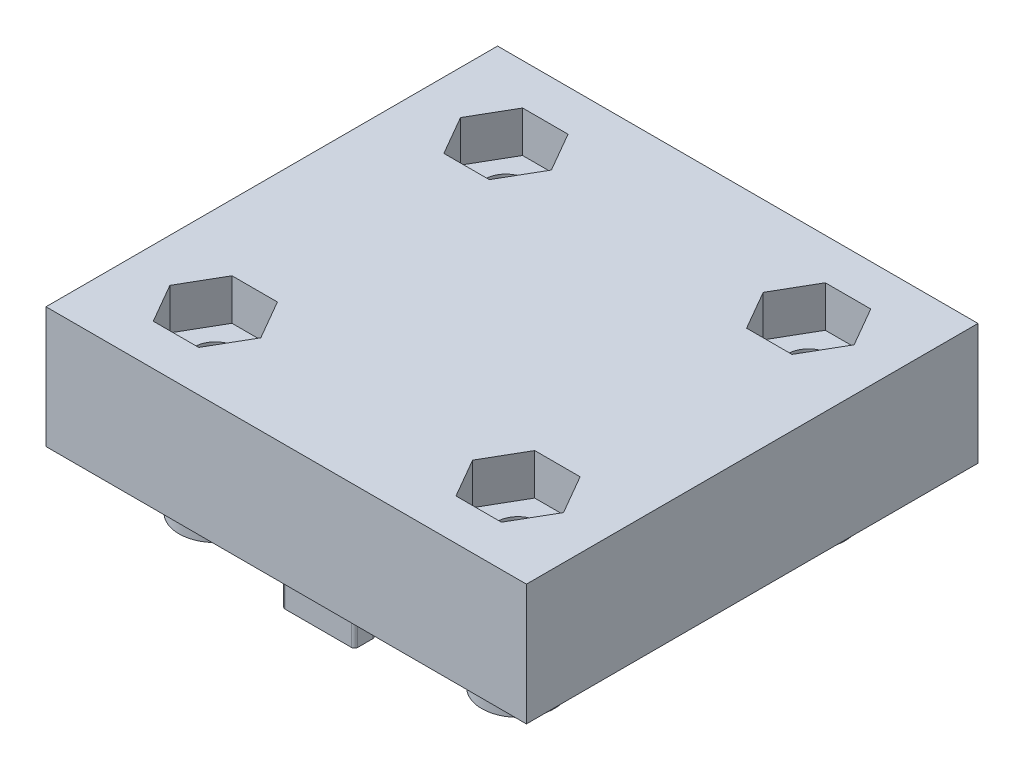
from build123d import *
from OCP.BRepFilletAPI import BRepFilletAPI_MakeChamfer

# Parameters (mm, degrees)
BOSS_EXTRUDE3_DEPTH       = 10
M4_CLEARANCE_HOLE1_D      = 4.5
SKETCH21_R                = 1.118017303
BOSS_EXTRUDE6_DEPTH       = 1
CUT_EXTRUDE11_DEPTH       = 15
SKETCH22_R                = 1.118017303
CUT_EXTRUDE8_DEPTH        = 1
CHAMFER1_SIZE             = 1
CHAMFER1_SIZE2            = 1.035530314
CUT_EXTRUDE10_DEPTH       = 3
SKETCH25_R                = 1.75
CUT_EXTRUDE12_DEPTH       = 76.875514918
CUT_EXTRUDE13_DEPTH       = 3.4
MIRROR3_COPY_1_DEPTH      = 3.4
SKETCH27_R                = 3
SKETCH27_R_2              = 1.7
BOSS_EXTRUDE7_DEPTH       = 4.4
MIRROR5_COPY_1_SKETCH_R   = 3
MIRROR5_COPY_1_SKETCH_R_2 = 1.7
MIRROR5_COPY_1_DEPTH      = 4.4
FILLET3_R                 = 2.1
CUT_EXTRUDE14_DEPTH       = 2
MIRROR7_COPY_1_DEPTH      = 2
CUT_EXTRUDE15_DEPTH       = 4
FILLET6_R                 = 0.25
FILLET7_R                 = 0.25
BOSS_EXTRUDE8_DEPTH       = 4.4
FILLET8_R                 = 0.25
FILLET9_R                 = 1
FILLET10_R                = 0.25
FILLET11_R                = 1
SKETCH32_W                = 148.301652658
SKETCH32_H                = 130.819582074
SKETCH32_W_2              = 39.676110034
SKETCH32_H_2              = 37.292287862
CUT_EXTRUDE16_DEPTH       = 40


with BuildPart() as part:
    # Sketch6 → Boss-Extrude3 (new body)
    with BuildSketch(Plane(origin=(0, 0, 0), x_dir=(1, 0, 0), z_dir=(0, 1, 0))):
        with BuildLine():
            Line((-40, 33.094010768), (40, 33.094010768))
            ThreePointArc((40, 33.094010768), (48.660254038, 28.094010768), (48.660254038, 18.094010768))
            Line((48.660254038, 18.094010768), (28.660254038, -16.547005384))
            Line((28.660254038, -16.547005384), (8.660254038, -51.188021535))
            ThreePointArc((8.660254038, -51.188021535), (0, -56.188021535), (-8.660254038, -51.188021535))
            Line((-8.660254038, -51.188021535), (-28.660254038, -16.547005384))
            Line((-28.660254038, -16.547005384), (-48.660254038, 18.094010768))
            ThreePointArc((-48.660254038, 18.094010768), (-48.660254038, 28.094010768), (-40, 33.094010768))
        make_face()
    extrude(amount=BOSS_EXTRUDE3_DEPTH)

    # M4 Clearance Hole1 (through all)
    with Locations(Plane(origin=(0, 0, 0), x_dir=(-1, 0, 0), z_dir=(0, -1, 0))):
        with Locations((-40, 23.094010768), (40, 23.094010768), (0, -46.188021535)):
            Hole(M4_CLEARANCE_HOLE1_D / 2)

    # Sketch21 → Boss-Extrude6 (add)
    with BuildSketch(Plane(origin=(0, 0, 0), x_dir=(-1, 0, 0), z_dir=(0, -1, 0))):
        with Locations(Location((0, 0, 0), (0, 0, 270))):
            Circle(SKETCH21_R)
    extrude(amount=BOSS_EXTRUDE6_DEPTH)

    # Sketch24 → Cut-Extrude11 (cut, symmetric)
    with BuildSketch(Plane(origin=(0, 0, 0), x_dir=(0, 0, -1), z_dir=(1, 0, 0))):
        Polygon((27.094010768, 10), (33.094010768, 2.214464559), (33.094010768, 10), align=None)
    extrude(amount=CUT_EXTRUDE11_DEPTH, both=True, mode=Mode.SUBTRACT)

    # Sketch22 → Cut-Extrude8 (cut)
    with BuildSketch(Plane(origin=(0, -1, 0), x_dir=(-1, 0, 0), z_dir=(0, -1, 0))):
        Circle(SKETCH22_R)
    extrude(amount=-CUT_EXTRUDE8_DEPTH, mode=Mode.SUBTRACT)

    # Chamfer1: one chamfer whose edges measure the first distance from different faces: ONE call of the kernel's chamfer builder (chamfer() names one face for all edges)
    chamfer1_edges_1 = [part.edges().sort_by_distance(p)[0] for p in [
        (-48.660254038, 10, -28.094010768),
    ]]
    chamfer1_side_1 = [part.faces().sort_by_distance(p)[0] for p in [
        (-48.660254038, 5, -28.094010768),
    ]]
    chamfer1_edges_2 = [part.edges().sort_by_distance(p)[0] for p in [
        (-28.660254038, 10, 16.547005384),
    ]]
    chamfer1_side_2 = [part.faces().sort_by_distance(p)[0] for p in [
        (-28.660254038, 5, 16.547005384),
    ]]
    chamfer1_edges_3 = [part.edges().sort_by_distance(p)[0] for p in [
        (0, 10, 56.188021535),
    ]]
    chamfer1_side_3 = [part.faces().sort_by_distance(p)[0] for p in [
        (0, 5, 56.188021535),
    ]]
    chamfer1_edges_4 = [part.edges().sort_by_distance(p)[0] for p in [
        (28.660254038, 10, 16.547005384),
    ]]
    chamfer1_side_4 = [part.faces().sort_by_distance(p)[0] for p in [
        (28.660254038, 5, 16.547005384),
    ]]
    chamfer1_edges_5 = [part.edges().sort_by_distance(p)[0] for p in [
        (-27.5, 10, -33.094010768),
        (27.5, 10, -33.094010768),
    ]]
    chamfer1_side_5 = [part.faces().sort_by_distance(p)[0] for p in [
        (0, 0.806225775, -33.094010768),
    ]]
    chamfer1_edges_6 = [part.edges().sort_by_distance(p)[0] for p in [
        (48.660254038, 10, -28.094010768),
    ]]
    chamfer1_side_6 = [part.faces().sort_by_distance(p)[0] for p in [
        (48.660254038, 5, -28.094010768),
    ]]
    chamfer1 = BRepFilletAPI_MakeChamfer(part.part.solid().wrapped)
    for e in chamfer1_edges_1:
        chamfer1.Add(CHAMFER1_SIZE, CHAMFER1_SIZE2, e.wrapped, chamfer1_side_1[0].wrapped)  # the first distance lies on this face
    for e in chamfer1_edges_2:
        chamfer1.Add(CHAMFER1_SIZE, CHAMFER1_SIZE2, e.wrapped, chamfer1_side_2[0].wrapped)  # the first distance lies on this face
    for e in chamfer1_edges_3:
        chamfer1.Add(CHAMFER1_SIZE, CHAMFER1_SIZE2, e.wrapped, chamfer1_side_3[0].wrapped)  # the first distance lies on this face
    for e in chamfer1_edges_4:
        chamfer1.Add(CHAMFER1_SIZE, CHAMFER1_SIZE2, e.wrapped, chamfer1_side_4[0].wrapped)  # the first distance lies on this face
    for e in chamfer1_edges_5:
        chamfer1.Add(CHAMFER1_SIZE, CHAMFER1_SIZE2, e.wrapped, chamfer1_side_5[0].wrapped)  # the first distance lies on this face
    for e in chamfer1_edges_6:
        chamfer1.Add(CHAMFER1_SIZE, CHAMFER1_SIZE2, e.wrapped, chamfer1_side_6[0].wrapped)  # the first distance lies on this face
    add(Compound.cast(chamfer1.Shape()), mode=Mode.REPLACE)

    # Sketch23 → Cut-Extrude10 (cut)
    with BuildSketch(Plane(origin=(0, 10, 0), x_dir=(1, 0, 0), z_dir=(0, 1, 0))):
        Polygon((38.239081679, 26.144010768), (36.478163358, 23.094010768), (38.239081679, 20.044010768), (41.760918321, 20.044010768), (43.521836642, 23.094010768), (41.760918321, 26.144010768), align=None)
        Polygon((-38.239081679, 20.044010768), (-36.478163358, 23.094010768), (-38.239081679, 26.144010768), (-41.760918321, 26.144010768), (-43.521836642, 23.094010768), (-41.760918321, 20.044010768), align=None)
        Polygon((3.521836642, -46.188021535), (1.760918321, -43.138021535), (-1.760918321, -43.138021535), (-3.521836642, -46.188021535), (-1.760918321, -49.238021535), (1.760918321, -49.238021535), align=None)
    extrude(amount=-CUT_EXTRUDE10_DEPTH, mode=Mode.SUBTRACT)

    # Sketch25 → Cut-Extrude12 (cut, symmetric)
    with BuildSketch(Plane.XZ):
        with Locations(Location((-12.5, -12, 0), (0, 0, 270))):
            Circle(SKETCH25_R)
        with Locations(Location((12.5, -12, 0), (0, 0, 90))):
            Circle(SKETCH25_R)
    cut_extrude12 = extrude(amount=CUT_EXTRUDE12_DEPTH, both=True, mode=Mode.SUBTRACT)

    # Mirror1: Cut-Extrude12 across plane
    add(cut_extrude12.mirror(Plane.XY), mode=Mode.SUBTRACT)

    # Sketch26 → Cut-Extrude13 (cut)
    with BuildSketch(Plane(origin=(0, 10, 0), x_dir=(1, 0, 0), z_dir=(0, 1, 0))):
        Polygon((-16.25277675, 12), (-14.376388375, 8.75), (-10.623611625, 8.75), (-8.74722325, 12), (-10.623611625, 15.25), (-14.376388375, 15.25), align=None)
    cut_extrude13 = extrude(amount=-CUT_EXTRUDE13_DEPTH, mode=Mode.SUBTRACT)

    # Mirror2: Cut-Extrude13 across plane
    add(cut_extrude13.mirror(Plane(origin=(0, 0, 0), x_dir=(0, 0, 1), z_dir=(1, 0, 0))), mode=Mode.SUBTRACT)

    # Mirror3: Cut-Extrude13 across plane
    add(cut_extrude13.mirror(Plane.XY), mode=Mode.SUBTRACT)

    # Mirror3 copy 1 sketch → Mirror3 copy 1 (cut)
    with BuildSketch(Plane(origin=(0, 10, 0), x_dir=(-1, 0, 0), z_dir=(0, 1, 0))):
        Polygon((-16.25277675, 12), (-14.376388375, 8.75), (-10.623611625, 8.75), (-8.74722325, 12), (-10.623611625, 15.25), (-14.376388375, 15.25), align=None)
    extrude(amount=-MIRROR3_COPY_1_DEPTH, mode=Mode.SUBTRACT)

    # Sketch27 → Boss-Extrude7 (add)
    with BuildSketch(Plane.XZ):
        with Locations(Location((-12.5, -12, 0), (0, 0, 90))):
            Circle(SKETCH27_R)
        with Locations(Location((-12.5, -12, 0), (0, 0, 270))):
            Circle(SKETCH27_R_2, mode=Mode.SUBTRACT)
    boss_extrude7 = extrude(amount=BOSS_EXTRUDE7_DEPTH)

    # Mirror4: Boss-Extrude7 across plane
    add(boss_extrude7.mirror(Plane.XY))

    # Mirror5: Boss-Extrude7 across plane
    add(boss_extrude7.mirror(Plane(origin=(0, 0, 0), x_dir=(0, 0, 1), z_dir=(1, 0, 0))))

    # Mirror5 copy 1 sketch → Mirror5 copy 1 (add)
    with BuildSketch(Plane(origin=(0, 0, 0), x_dir=(-1, 0, 0), z_dir=(0, -1, 0))):
        with Locations(Location((-12.5, -12, 0), (0, 0, 90))):
            Circle(MIRROR5_COPY_1_SKETCH_R)
        with Locations(Location((-12.5, -12, 0), (0, 0, 270))):
            Circle(MIRROR5_COPY_1_SKETCH_R_2, mode=Mode.SUBTRACT)
    extrude(amount=MIRROR5_COPY_1_DEPTH)

    # Fillet3
    fillet3_edges = [part.edges().sort_by_distance(p)[0] for p in [
        (-12.5, 0, -15),
        (-12.5, 0, 15),
        (12.5, 0, -15),
        (12.5, 0, 15),
    ]]
    fillet(fillet3_edges, radius=FILLET3_R)

    # Sketch28 → Cut-Extrude14 (cut)
    with BuildSketch(Plane.XZ.offset(4.4)):
        Polygon((10.05, -12), (10.05, -15.988715384), (8.221886026, -15.988715384), (8.221886026, -5.587036016), (10.05, -5.587036016), align=None)
    cut_extrude14 = extrude(amount=-CUT_EXTRUDE14_DEPTH, mode=Mode.SUBTRACT)

    # Mirror6: Cut-Extrude14 across plane
    add(cut_extrude14.mirror(Plane(origin=(0, 0, 0), x_dir=(0, 0, 1), z_dir=(1, 0, 0))), mode=Mode.SUBTRACT)

    # Mirror7: Cut-Extrude14 across plane
    add(cut_extrude14.mirror(Plane.XY), mode=Mode.SUBTRACT)

    # Mirror7 copy 1 sketch → Mirror7 copy 1 (cut)
    with BuildSketch(Plane(origin=(0, -4.4, 0), x_dir=(-1, 0, 0), z_dir=(0, -1, 0))):
        Polygon((10.05, -12), (10.05, -15.988715384), (8.221886026, -15.988715384), (8.221886026, -5.587036016), (10.05, -5.587036016), align=None)
    extrude(amount=-MIRROR7_COPY_1_DEPTH, mode=Mode.SUBTRACT)

    # Sketch29 → Cut-Extrude15 (cut)
    with BuildSketch(Plane.XZ.offset(4.4)):
        Polygon((12.5, -9.9), (6.953571085, -9.9), (6.953571085, -8.097822779), (18.670819989, -8.097822779), (18.670819989, -9.9), align=None)
    extrude(amount=-CUT_EXTRUDE15_DEPTH, mode=Mode.SUBTRACT)

    # Fillet6
    fillet6_edges = [part.edges().sort_by_distance(p)[0] for p in [
        (9.5, -2.4, -12),
        (10.05, -3.4, -13.731328969),
    ]]
    fillet(fillet6_edges, radius=FILLET6_R)

    # Fillet7
    fillet7_edges = [part.edges().sort_by_distance(p)[0] for p in [
        (-9.5, -2.4, -12),
        (-10.05, -3.4, -10.268671031),
        (-10.05, -3.4, -13.731328969),
        (-9.5, -2.4, 12),
        (-10.05, -3.4, 13.731328969),
        (-10.05, -3.4, 10.268671031),
        (9.5, -2.4, 12),
        (10.05, -3.4, 10.268671031),
        (10.05, -3.4, 13.731328969),
    ]]
    fillet(fillet7_edges, radius=FILLET7_R)

    # Sketch30 → Boss-Extrude8 (add)
    with BuildSketch(Plane.XZ):
        Polygon((3, -15), (3, -14.25), (-3, -14.25), (-3, -15), (-3, -16), (3, -16), align=None)
    boss_extrude8 = extrude(amount=BOSS_EXTRUDE8_DEPTH)

    # Fillet8
    fillet8_edges = [part.edges().sort_by_distance(p)[0] for p in [
        (3, -2.2, -16),
        (3, -2.2, -14.25),
        (-3, -2.2, -14.25),
        (-3, -2.2, -16),
    ]]
    fillet(fillet8_edges, radius=FILLET8_R)

    # Mirror8: Boss-Extrude8 across plane
    add(boss_extrude8.mirror(Plane.XY))

    # Fillet9
    fillet9_edges = [part.edges().sort_by_distance(p)[0] for p in [
        (0, 0, -14.25),
        (3, 0, -15.125),
        (0, 0, -16),
        (-3, 0, -15.125),
        (2.926776695, 0, -14.323223305),
        (2.926776695, 0, -15.926776695),
        (-2.926776695, 0, -15.926776695),
        (-2.926776695, 0, -14.323223305),
    ]]
    fillet(fillet9_edges, radius=FILLET9_R)

    # Fillet10
    fillet10_edges = [part.edges().sort_by_distance(p)[0] for p in [
        (3, -2.2, 16),
        (-3, -2.2, 16),
        (-3, -2.2, 14.25),
        (3, -2.2, 14.25),
    ]]
    fillet(fillet10_edges, radius=FILLET10_R)

    # Fillet11
    fillet11_edges = [part.edges().sort_by_distance(p)[0] for p in [
        (3, 0, 15.125),
        (0, 0, 14.25),
        (0, 0, 16),
        (-3, 0, 15.125),
        (2.926776695, 0, 14.323223305),
        (2.926776695, 0, 15.926776695),
        (-2.926776695, 0, 15.926776695),
        (-2.926776695, 0, 14.323223305),
    ]]
    fillet(fillet11_edges, radius=FILLET11_R)

    # Sketch32 → Cut-Extrude16 (cut)
    with BuildSketch(Plane(origin=(0, -20, 0), x_dir=(-1, 0, 0), z_dir=(0, -1, 0))):
        Rectangle(SKETCH32_W, SKETCH32_H)
        Rectangle(SKETCH32_W_2, SKETCH32_H_2, mode=Mode.SUBTRACT)
    extrude(amount=-CUT_EXTRUDE16_DEPTH, mode=Mode.SUBTRACT)


solid = part.part
